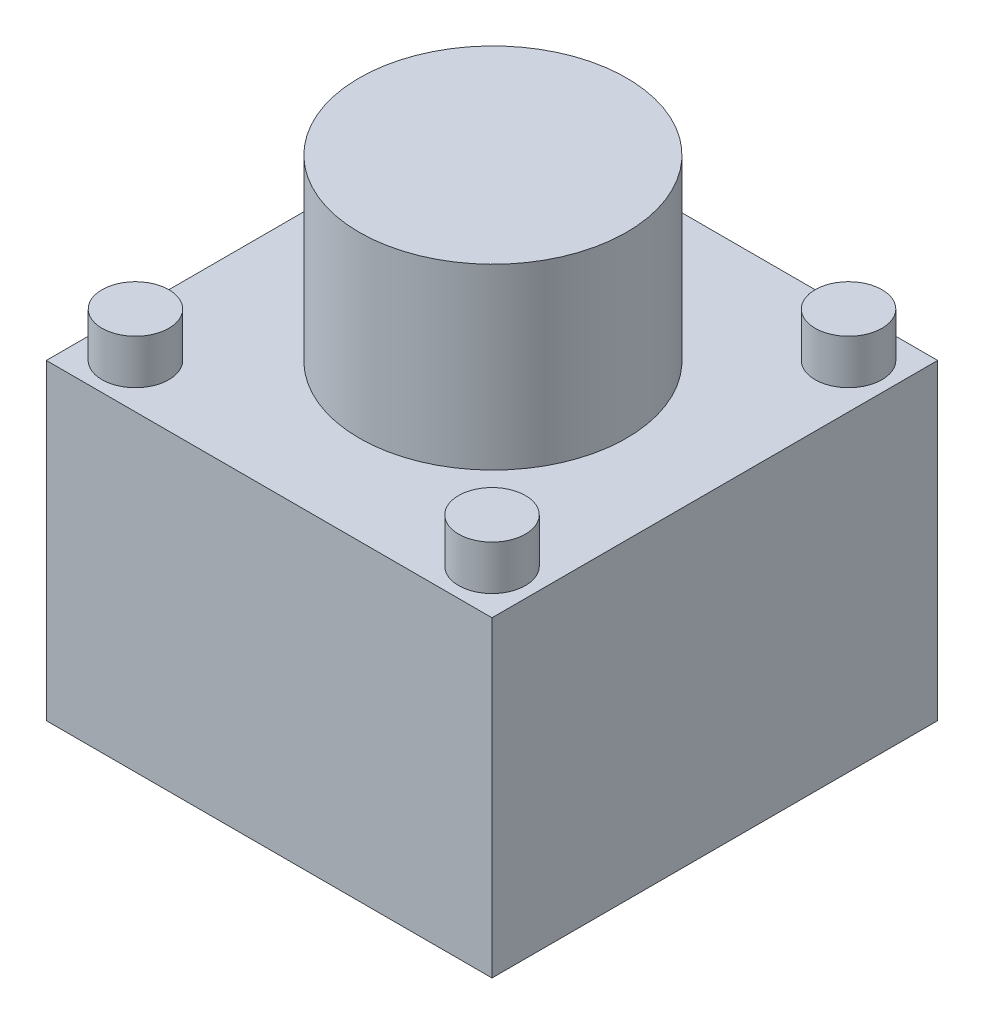
from build123d import *

# Parameters (mm, degrees)
SKETCH1_W           = 10
SKETCH1_H           = 10
BOSS_EXTRUDE1_DEPTH = 7
SKETCH3_R           = 0.75
BOSS_EXTRUDE2_DEPTH = 1
SKETCH4_R           = 3
BOSS_EXTRUDE4_DEPTH = 4


with BuildPart() as part:
    # Sketch1 → Boss-Extrude1 (new body)
    with BuildSketch(Plane(origin=(0, 0, 0), x_dir=(1, 0, 0), z_dir=(0, 1, 0))):
        with Locations((-3.108910891, -0.430693069)):
            Rectangle(SKETCH1_W, SKETCH1_H)
    extrude(amount=BOSS_EXTRUDE1_DEPTH)

    # Sketch3 → Boss-Extrude2 (add)
    with BuildSketch(Plane(origin=(0, 7, 0), x_dir=(1, 0, 0), z_dir=(0, 1, 0))):
        with Locations((-7.108910891, 3.569306931)):
            Circle(SKETCH3_R)
        with Locations((-7.108910891, -4.430693069)):
            Circle(SKETCH3_R)
        with Locations((0.891089109, -4.430693069)):
            Circle(SKETCH3_R)
        with Locations((0.891089109, 3.569306931)):
            Circle(SKETCH3_R)
    extrude(amount=BOSS_EXTRUDE2_DEPTH)

    # Sketch4 → Boss-Extrude4 (add)
    with BuildSketch(Plane(origin=(0, 7, 0), x_dir=(1, 0, 0), z_dir=(0, 1, 0))):
        with Locations((-3.088623083, -0.430693069)):
            Circle(SKETCH4_R)
    extrude(amount=BOSS_EXTRUDE4_DEPTH)


solid = part.part
